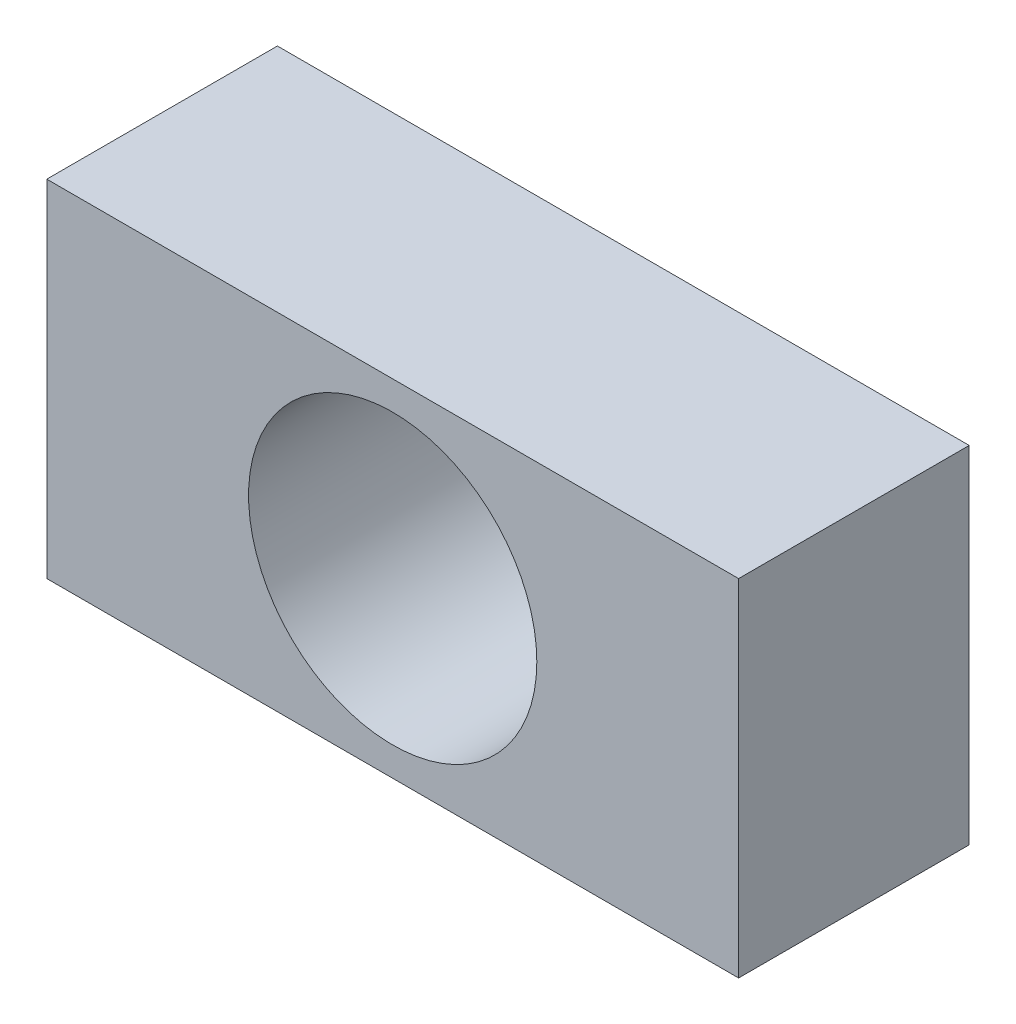
from build123d import *

# Parameters (mm, degrees)
SKETCH1_W           = 60
SKETCH1_H           = 30
SKETCH1_R           = 12.5
BOSS_EXTRUDE2_DEPTH = 20
SKETCH2_R           = 4
CUT_EXTRUDE1_DEPTH  = 10


with BuildPart() as part:
    # Sketch1 → Boss-Extrude2 (new body)
    with BuildSketch(Plane.XY):
        with Locations((2.571428571, 3)):
            Rectangle(SKETCH1_W, SKETCH1_H)
        with Locations((2.571428571, 3)):
            Circle(SKETCH1_R, mode=Mode.SUBTRACT)
    extrude(amount=BOSS_EXTRUDE2_DEPTH)

    # Sketch2 → Cut-Extrude1 (cut)
    with BuildSketch(Plane.XZ.offset(12)):
        with Locations((-20.428571429, 10)):
            Circle(SKETCH2_R)
        with Locations((25.571428571, 10)):
            Circle(SKETCH2_R)
    extrude(amount=-CUT_EXTRUDE1_DEPTH, mode=Mode.SUBTRACT)


solid = part.part
